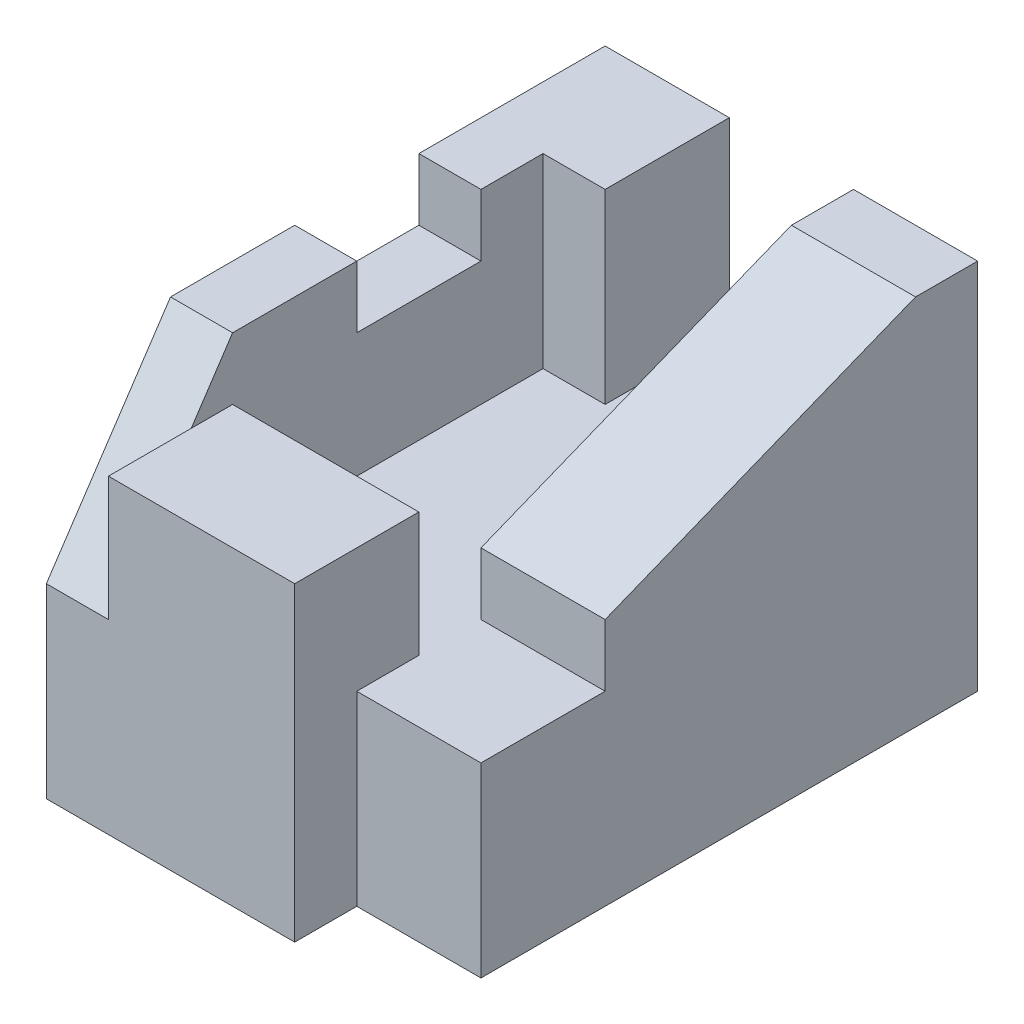
from build123d import *

# Parameters (mm, degrees)
SKETCH1_W           = 6
SKETCH1_H           = 6
BOSS_EXTRUDE1_DEPTH = 9
CUT_EXTRUDE1_DEPTH  = 3
SKETCH3_W           = 1
SKETCH3_H           = 2
CUT_EXTRUDE2_DEPTH  = 1
CUT_EXTRUDE3_DEPTH  = 1
SKETCH5_W           = 2
SKETCH5_H           = 1
CUT_EXTRUDE4_DEPTH  = 3
SKETCH6_W           = 1
SKETCH6_H           = 3
CUT_EXTRUDE5_DEPTH  = 2
CUT_EXTRUDE6_DEPTH  = 2


with BuildPart() as part:
    # Sketch1 → Boss-Extrude1 (new body)
    with BuildSketch(Plane.XY):
        Rectangle(SKETCH1_W, SKETCH1_H)
    extrude(amount=BOSS_EXTRUDE1_DEPTH)

    # Sketch2 → Cut-Extrude1 (cut)
    with BuildSketch(Plane(origin=(0, 3, 0), x_dir=(1, 0, 0), z_dir=(0, 1, 0))):
        Polygon((1, 0), (-1, 0), (-1, -2), (-2, -2), (-2, -7), (1, -7), (1, -9), (3, -9), (3, -6), (1, -6), align=None)
    extrude(amount=-CUT_EXTRUDE1_DEPTH, mode=Mode.SUBTRACT)

    # Sketch3 → Cut-Extrude2 (cut)
    with BuildSketch(Plane(origin=(0, 3, 0), x_dir=(1, 0, 0), z_dir=(0, 1, 0))):
        with Locations((-2.5, -4)):
            Rectangle(SKETCH3_W, SKETCH3_H)
    extrude(amount=-CUT_EXTRUDE2_DEPTH, mode=Mode.SUBTRACT)

    # Sketch4 → Cut-Extrude3 (cut)
    with BuildSketch(Plane.ZY.offset(3)):
        Polygon((7, 3), (9, 0), (9, 3), align=None)
    extrude(amount=-CUT_EXTRUDE3_DEPTH, mode=Mode.SUBTRACT)

    # Sketch5 → Cut-Extrude4 (cut)
    with BuildSketch(Plane(origin=(1, 0, 0), x_dir=(0, 0, -1), z_dir=(1, 0, 0))):
        with Locations((-8, 2.5)):
            Rectangle(SKETCH5_W, SKETCH5_H)
    extrude(amount=-CUT_EXTRUDE4_DEPTH, mode=Mode.SUBTRACT)

    # Sketch6 → Cut-Extrude5 (cut)
    with BuildSketch(Plane(origin=(3, 0, 0), x_dir=(0, 0, -1), z_dir=(1, 0, 0))):
        with Locations((-8.5, -1.5)):
            Rectangle(SKETCH6_W, SKETCH6_H)
    extrude(amount=-CUT_EXTRUDE5_DEPTH, mode=Mode.SUBTRACT)

    # Sketch7 → Cut-Extrude6 (cut)
    with BuildSketch(Plane(origin=(3, 0, 0), x_dir=(0, 0, -1), z_dir=(1, 0, 0))):
        Polygon((-1, 3), (-6, 1), (-6, 3), align=None)
    extrude(amount=-CUT_EXTRUDE6_DEPTH, mode=Mode.SUBTRACT)


solid = part.part
